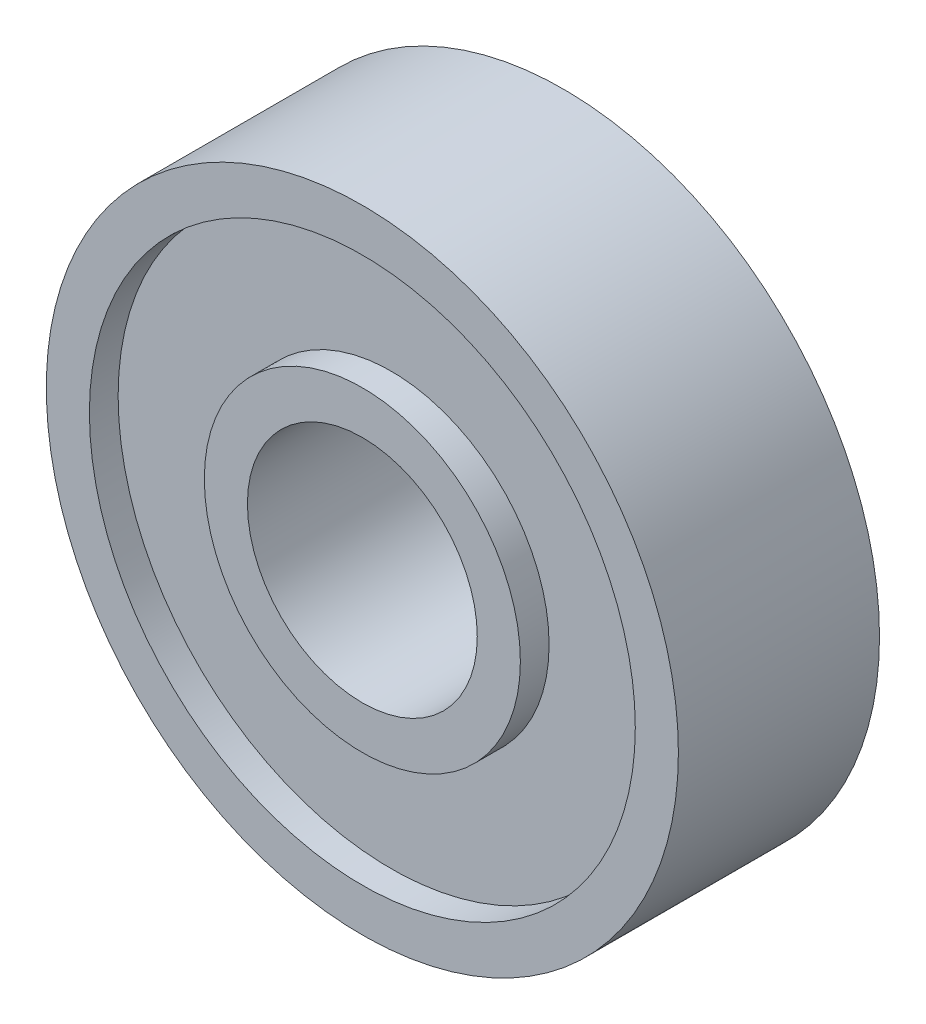
from build123d import *

# Parameters (mm, degrees)
SKETCH1_R           = 11
SKETCH1_R_2         = 4
BOSS_EXTRUDE1_DEPTH = 7
SKETCH2_R           = 9.5
SKETCH2_R_2         = 5.5
CUT_EXTRUDE1_DEPTH  = 1
SKETCH3_R           = 9.5
SKETCH3_R_2         = 5.5
CUT_EXTRUDE2_DEPTH  = 1


with BuildPart() as part:
    # Sketch1 → Boss-Extrude1 (new body)
    with BuildSketch(Plane.XY):
        Circle(SKETCH1_R)
        Circle(SKETCH1_R_2, mode=Mode.SUBTRACT)
    extrude(amount=BOSS_EXTRUDE1_DEPTH)

    # Sketch2 → Cut-Extrude1 (cut)
    with BuildSketch(Plane.XY.offset(7)):
        Circle(SKETCH2_R)
        Circle(SKETCH2_R_2, mode=Mode.SUBTRACT)
    extrude(amount=-CUT_EXTRUDE1_DEPTH, mode=Mode.SUBTRACT)

    # Sketch3 → Cut-Extrude2 (cut)
    with BuildSketch(Plane(origin=(0, 0, 0), x_dir=(-1, 0, 0), z_dir=(0, 0, -1))):
        Circle(SKETCH3_R)
        Circle(SKETCH3_R_2, mode=Mode.SUBTRACT)
    extrude(amount=-CUT_EXTRUDE2_DEPTH, mode=Mode.SUBTRACT)


solid = part.part
